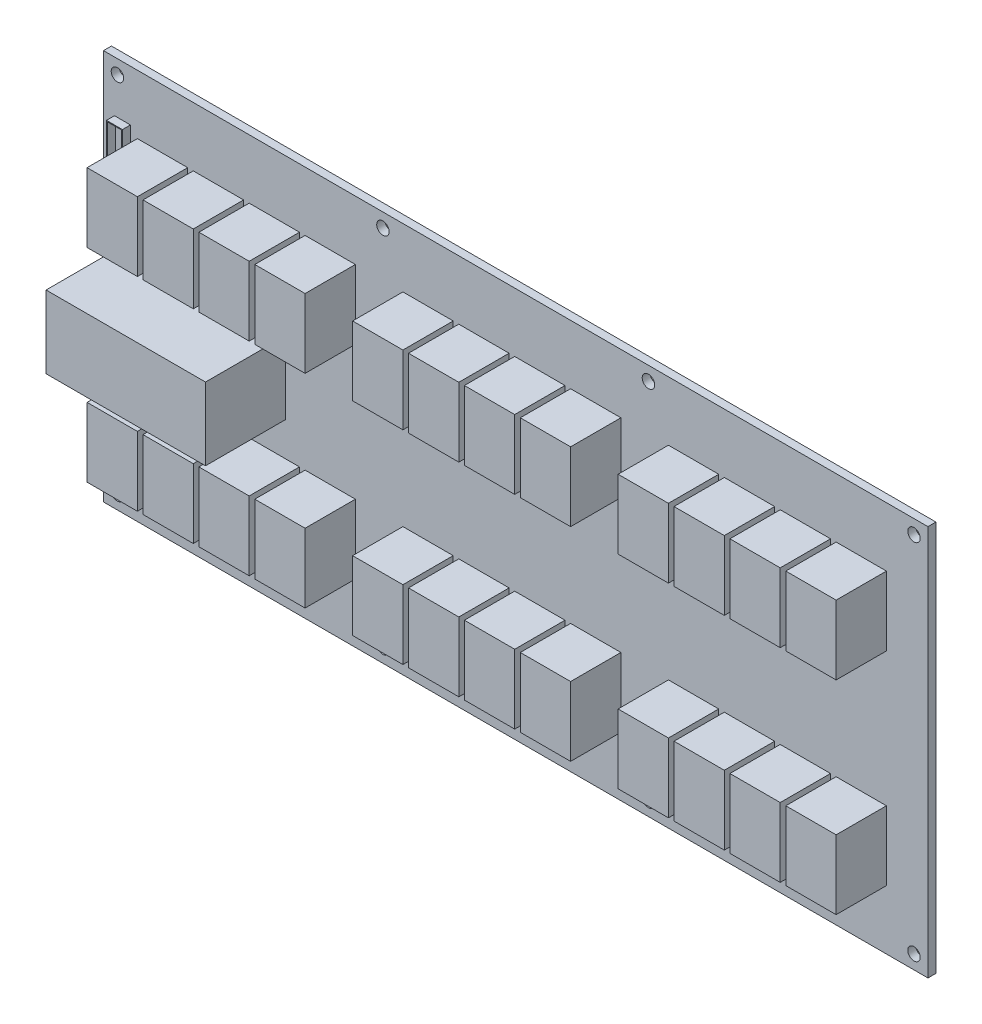
from build123d import *

# Parameters (mm, degrees)
SKETCH1_W                       = 262.255
SKETCH1_H                       = 124.333
BOSS_EXTRUDE1_DEPTH             = 2.54
F_5_32_0_15625_DIAMETER_HOLE1_D = 3.96875
SKETCH12_W                      = 5.08
SKETCH12_H                      = 26.924
SKETCH12_W_2                    = 4.367686067
SKETCH12_H_2                    = 26.272785271
BOSS_EXTRUDE2_DEPTH             = 2.54
SKETCH13_W                      = 50.710492808
SKETCH13_H                      = 23.078831344
BOSS_EXTRUDE3_DEPTH             = 25.4
SKETCH14_W                      = 15.728561486
SKETCH14_H                      = 17.117120152
CUT_EXTRUDE1_DEPTH              = 25.4
SKETCH16_W                      = 16.002
SKETCH16_H                      = 21.9964
BOSS_EXTRUDE5_DEPTH             = 16.002
LPATTERN1_COUNT                 = 4
LPATTERN1_PITCH                 = 17.78
MIRROR1_COPY_1_SKETCH_W         = 16.002
MIRROR1_COPY_1_SKETCH_H         = 21.9964
MIRROR1_COPY_1_DEPTH            = 16.002
MIRROR1_COPY_2_SKETCH_W         = 16.002
MIRROR1_COPY_2_SKETCH_H         = 21.9964
MIRROR1_COPY_2_DEPTH            = 16.002
MIRROR1_COPY_3_SKETCH_W         = 16.002
MIRROR1_COPY_3_SKETCH_H         = 21.9964
MIRROR1_COPY_3_DEPTH            = 16.002


with BuildPart() as part:
    # Sketch1 → Boss-Extrude1 (new body)
    with BuildSketch(Plane.XY):
        with Locations((131.1275, 62.1665)):
            Rectangle(SKETCH1_W, SKETCH1_H)
    extrude(amount=BOSS_EXTRUDE1_DEPTH)

    # 5/32 (0.15625) Diameter Hole1 (through all)
    with Locations(Plane.XY.offset(2.54)):
        with Locations((4.445, 119.888), (88.9, 119.888), (173.355, 119.888), (257.81, 119.888), (4.445, 4.445), (88.9, 4.445), (173.355, 4.445), (257.81, 4.445)):
            Hole(F_5_32_0_15625_DIAMETER_HOLE1_D / 2)

    # Sketch12 → Boss-Extrude2 (add)
    with BuildSketch(Plane.XY.offset(2.54)):
        with Locations((6.044810111, 94.689164449)):
            Rectangle(SKETCH12_W, SKETCH12_H)
        with Locations((6.063998692, 94.748985924)):
            Rectangle(SKETCH12_W_2, SKETCH12_H_2, mode=Mode.SUBTRACT)
    extrude(amount=BOSS_EXTRUDE2_DEPTH)

    # Sketch13 → Boss-Extrude3 (add)
    with BuildSketch(Plane.XY.offset(2.54)):
        with Locations((32.501526889, 63.129188548)):
            Rectangle(SKETCH13_W, SKETCH13_H)
    extrude(amount=BOSS_EXTRUDE3_DEPTH)

    # Sketch14 → Cut-Extrude1 (cut)
    with BuildSketch(Plane.ZY.offset(-7.146280485)):
        with Locations((15.411737976, 63.690176449)):
            Rectangle(SKETCH14_W, SKETCH14_H)
    extrude(amount=-CUT_EXTRUDE1_DEPTH, mode=Mode.SUBTRACT)

    # Sketch16 → Boss-Extrude5 (add)
    with BuildSketch(Plane.XY.offset(2.54)):
        with Locations((103.251, 94.491464858)):
            Rectangle(SKETCH16_W, SKETCH16_H)
        with Locations((18.796, 94.491464858)):
            Rectangle(SKETCH16_W, SKETCH16_H)
        with Locations((187.706, 94.491464858)):
            Rectangle(SKETCH16_W, SKETCH16_H)
    boss_extrude5 = extrude(amount=BOSS_EXTRUDE5_DEPTH)

    # LPattern1: Boss-Extrude5 ×4
    with Locations(*[(i * LPATTERN1_PITCH, 0, 0) for i in range(1, LPATTERN1_COUNT)]):
        add(boss_extrude5)

    # Mirror1: Boss-Extrude5 across plane
    add(boss_extrude5.mirror(Plane.ZX.offset(62.1665)))

    # Mirror1 copy 1 sketch → Mirror1 copy 1 (add)
    with BuildSketch(Plane(origin=(17.78, 124.333, 2.54), x_dir=(1, 0, 0), z_dir=(0, 0, 1))):
        with Locations((103.251, -94.491464858)):
            Rectangle(MIRROR1_COPY_1_SKETCH_W, MIRROR1_COPY_1_SKETCH_H)
        with Locations((18.796, -94.491464858)):
            Rectangle(MIRROR1_COPY_1_SKETCH_W, MIRROR1_COPY_1_SKETCH_H)
        with Locations((187.706, -94.491464858)):
            Rectangle(MIRROR1_COPY_1_SKETCH_W, MIRROR1_COPY_1_SKETCH_H)
    extrude(amount=MIRROR1_COPY_1_DEPTH)

    # Mirror1 copy 2 sketch → Mirror1 copy 2 (add)
    with BuildSketch(Plane(origin=(35.56, 124.333, 2.54), x_dir=(1, 0, 0), z_dir=(0, 0, 1))):
        with Locations((103.251, -94.491464858)):
            Rectangle(MIRROR1_COPY_2_SKETCH_W, MIRROR1_COPY_2_SKETCH_H)
        with Locations((18.796, -94.491464858)):
            Rectangle(MIRROR1_COPY_2_SKETCH_W, MIRROR1_COPY_2_SKETCH_H)
        with Locations((187.706, -94.491464858)):
            Rectangle(MIRROR1_COPY_2_SKETCH_W, MIRROR1_COPY_2_SKETCH_H)
    extrude(amount=MIRROR1_COPY_2_DEPTH)

    # Mirror1 copy 3 sketch → Mirror1 copy 3 (add)
    with BuildSketch(Plane(origin=(53.34, 124.333, 2.54), x_dir=(1, 0, 0), z_dir=(0, 0, 1))):
        with Locations((103.251, -94.491464858)):
            Rectangle(MIRROR1_COPY_3_SKETCH_W, MIRROR1_COPY_3_SKETCH_H)
        with Locations((18.796, -94.491464858)):
            Rectangle(MIRROR1_COPY_3_SKETCH_W, MIRROR1_COPY_3_SKETCH_H)
        with Locations((187.706, -94.491464858)):
            Rectangle(MIRROR1_COPY_3_SKETCH_W, MIRROR1_COPY_3_SKETCH_H)
    extrude(amount=MIRROR1_COPY_3_DEPTH)


solid = part.part
